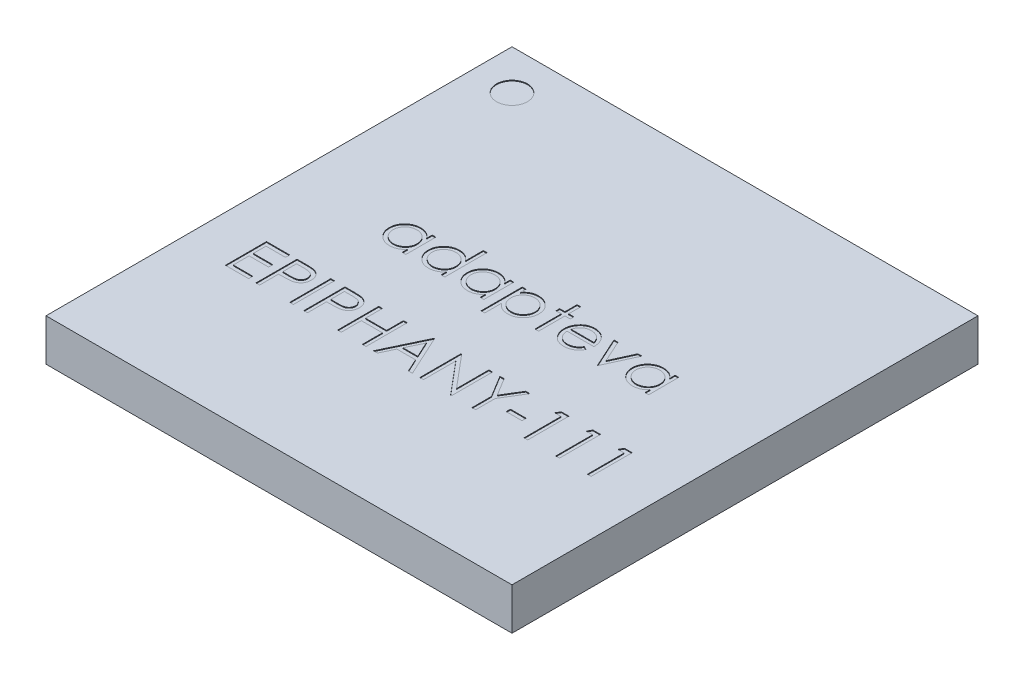
from build123d import *

# Parameters (mm, degrees)
SKETCH1_W           = 15.000224
SKETCH1_H           = 15.000224
BOSS_EXTRUDE1_DEPTH = 1.35
SKETCH2_R           = 0.498417109
SKETCH2_W           = 0.118723291
SKETCH2_H           = 1.322916667
SKETCH2_W_2         = 0.508814103
SKETCH2_H_2         = 0.135683761
CUT_EXTRUDE1_DEPTH  = 0.0254


with BuildPart() as part:
    # Sketch1 → Boss-Extrude1 (new body)
    with BuildSketch(Plane(origin=(0, 0, 0), x_dir=(1, 0, 0), z_dir=(0, 1, 0))):
        with Locations((7.500112, 7.500112)):
            Rectangle(SKETCH1_W, SKETCH1_H)
    extrude(amount=BOSS_EXTRUDE1_DEPTH)

    # Sketch2 → Cut-Extrude1 (cut)
    with BuildSketch(Plane(origin=(0, 1.35, 0), x_dir=(1, 0, 0), z_dir=(0, 1, 0))):
        with Locations((1.283347706, 13.716876294)):
            Circle(SKETCH2_R)
        with BuildLine():
            Line((4.082577278, 8.466858795), (4.082577278, 7.500112))
            Line((4.082577278, 7.500112), (3.963853987, 7.500112))
            Line((3.963853987, 7.500112), (3.963853987, 7.667331635))
            add(Edge.make_bspline(
                [(3.963853987, 7.667331635), (3.950466528, 7.652197622), (3.924340732, 7.622663405), (3.880706738, 7.584078774), (3.83445448, 7.552185777), (3.785808445, 7.526426732), (3.734812562, 7.507077353), (3.681579874, 7.493324252), (3.626088667, 7.484481939), (3.588195664, 7.483598978), (3.568993043, 7.48315153)],
                knots=[0, 0, 0, 0, 6.0575e-05, 0.000118214, 0.000174228, 0.000228757, 0.000282945, 0.000337452, 0.000393484, 0.000451052, 0.000451052, 0.000451052, 0.000451052], degree=3))
            add(Edge.make_bspline(
                [(3.568993043, 7.48315153), (3.551920632, 7.483615069), (3.518253081, 7.48452919), (3.46872721, 7.491620894), (3.421067342, 7.503009552), (3.375228441, 7.51884709), (3.331507124, 7.539855317), (3.289529052, 7.565006325), (3.249511695, 7.594957472), (3.212065012, 7.62919759), (3.177581488, 7.666388552), (3.147320233, 7.70605547), (3.122089158, 7.748026817), (3.100990497, 7.791771194), (3.084738902, 7.837625345), (3.073409582, 7.885430703), (3.06632614, 7.935130745), (3.065412397, 7.968974552), (3.064949073, 7.986135471)],
                knots=[0, 0, 0, 0, 5.1202e-05, 0.000100973, 0.000149758, 0.000198033, 0.00024616, 0.000295017, 0.000344626, 0.000395841, 0.00044704, 0.000496597, 0.000545227, 0.000593707, 0.00064207, 0.000690856, 0.000740889, 0.000792355, 0.000792355, 0.000792355, 0.000792355], degree=3))
            add(Edge.make_bspline(
                [(3.064949073, 7.986135471), (3.065422666, 8.002941692), (3.066358935, 8.036166685), (3.073333812, 8.085030955), (3.085062795, 8.132095893), (3.101522844, 8.177209975), (3.122629774, 8.220427792), (3.148304973, 8.261779909), (3.178550297, 8.301380246), (3.21341951, 8.338297644), (3.251192474, 8.372398889), (3.291601429, 8.402035641), (3.333641181, 8.427630997), (3.377963807, 8.447910734), (3.423913278, 8.464318342), (3.471898658, 8.475670089), (3.521720297, 8.482359255), (3.555545572, 8.483327919), (3.572703146, 8.483819265)],
                knots=[0, 0, 0, 0, 5.0408e-05, 9.9654e-05, 0.00014773, 0.000195684, 0.000243448, 0.000291765, 0.000341482, 0.000392667, 0.000443901, 0.000493936, 0.000542793, 0.000591287, 0.0006399, 0.000688943, 0.000738941, 0.000790407, 0.000790407, 0.000790407, 0.000790407], degree=3))
            add(Edge.make_bspline(
                [(3.572703146, 8.483819265), (3.59243345, 8.483275829), (3.631123644, 8.482210177), (3.687717267, 8.473341825), (3.741255507, 8.458359428), (3.792151646, 8.437979897), (3.840222917, 8.410898384), (3.885014224, 8.37673691), (3.926994332, 8.335710926), (3.95132855, 8.304198883), (3.963853987, 8.287978837)],
                knots=[0, 0, 0, 0, 5.9168e-05, 0.000116027, 0.000171322, 0.000225651, 0.000280117, 0.0003363, 0.000394205, 0.000455625, 0.000455625, 0.000455625, 0.000455625], degree=3))
            Line((3.963853987, 8.287978837), (3.963853987, 8.466858795))
            Line((3.963853987, 8.466858795), (4.082577278, 8.466858795))
        make_face()
        with BuildLine():
            add(Edge.make_bspline(
                [(3.57429319, 8.365095974), (3.556938663, 8.364478498), (3.522683588, 8.363259698), (3.472396123, 8.353744717), (3.424274684, 8.337913337), (3.378559948, 8.316262142), (3.335974044, 8.289036995), (3.297914234, 8.256107186), (3.264069225, 8.218371172), (3.235604494, 8.175999243), (3.212400348, 8.130574786), (3.196084238, 8.08309174), (3.18532354, 8.034406525), (3.184224189, 8.00138551), (3.183672363, 7.984810434)],
                knots=[0, 0, 0, 0, 5.2039e-05, 0.000102716, 0.000152915, 0.00020365, 0.000254077, 0.000304064, 0.000354175, 0.0004057, 0.00045678, 0.000506731, 0.000556003, 0.000605661, 0.000605661, 0.000605661, 0.000605661], degree=3))
            add(Edge.make_bspline(
                [(3.183672363, 7.984810434), (3.184377249, 7.968334412), (3.185784256, 7.935446947), (3.195895382, 7.88669536), (3.212858905, 7.839201123), (3.236006947, 7.793367355), (3.264992665, 7.750813246), (3.298590459, 7.712357902), (3.337125238, 7.67928892), (3.379809147, 7.651606861), (3.425396088, 7.629244837), (3.473336295, 7.613685206), (3.522728575, 7.603639437), (3.556312641, 7.602466019), (3.573233161, 7.601874821)],
                knots=[0, 0, 0, 0, 4.9412e-05, 9.863e-05, 0.000148668, 0.000200341, 0.000252234, 0.000302742, 0.000353102, 0.00040404, 0.000455005, 0.000504951, 0.000554897, 0.000605614, 0.000605614, 0.000605614, 0.000605614], degree=3))
            add(Edge.make_bspline(
                [(3.573233161, 7.601874821), (3.590410857, 7.602502247), (3.62457559, 7.603750137), (3.675012245, 7.613305853), (3.723958257, 7.629093465), (3.770746882, 7.650977956), (3.814333634, 7.678100528), (3.853453368, 7.709853208), (3.88653232, 7.746782686), (3.91457536, 7.787368428), (3.936564282, 7.83186076), (3.952581424, 7.8792341), (3.962051204, 7.929490097), (3.96324475, 7.963834498), (3.963853987, 7.981365339)],
                knots=[0, 0, 0, 0, 5.151e-05, 0.000102448, 0.000153402, 0.00020545, 0.000256996, 0.000307079, 0.000356048, 0.000405224, 0.000454645, 0.000504424, 0.000554841, 0.000607408, 0.000607408, 0.000607408, 0.000607408], degree=3))
            add(Edge.make_bspline(
                [(3.963853987, 7.981365339), (3.96349126, 7.994722197), (3.962777298, 8.021012722), (3.957322886, 8.059614492), (3.948646471, 8.096555513), (3.936420388, 8.131874625), (3.920359695, 8.16537655), (3.900989259, 8.197301841), (3.877968449, 8.227484453), (3.851667847, 8.255508769), (3.822879214, 8.281069961), (3.792416396, 8.303886207), (3.759918477, 8.322629583), (3.725931978, 8.338142206), (3.690397932, 8.350486587), (3.653027192, 8.358721817), (3.61421698, 8.364376462), (3.587741238, 8.364853612), (3.57429319, 8.365095974)],
                knots=[0, 0, 0, 0, 4.0059e-05, 7.8849e-05, 0.000116709, 0.000153753, 0.000190737, 0.000227959, 0.000265591, 0.000304403, 0.00034307, 0.000380967, 0.000418375, 0.000455374, 0.00049292, 0.000530977, 0.00057003, 0.000610342, 0.000610342, 0.000610342, 0.000610342], degree=3))
        make_face(mode=Mode.SUBTRACT)
        with BuildLine():
            Line((5.337652064, 8.856949607), (5.337652064, 7.500112))
            Line((5.337652064, 7.500112), (5.218928774, 7.500112))
            Line((5.218928774, 7.500112), (5.218928774, 7.667331635))
            add(Edge.make_bspline(
                [(5.218928774, 7.667331635), (5.205541314, 7.652197622), (5.179415518, 7.622663405), (5.135781524, 7.584078774), (5.089529267, 7.552185777), (5.040883232, 7.526426732), (4.989887348, 7.507077353), (4.93665466, 7.493324252), (4.881163454, 7.484481939), (4.843270451, 7.483598978), (4.824067829, 7.48315153)],
                knots=[0, 0, 0, 0, 6.0575e-05, 0.000118214, 0.000174228, 0.000228757, 0.000282945, 0.000337452, 0.000393484, 0.000451052, 0.000451052, 0.000451052, 0.000451052], degree=3))
            add(Edge.make_bspline(
                [(4.824067829, 7.48315153), (4.806995418, 7.483615069), (4.773327868, 7.48452919), (4.723801996, 7.491620894), (4.676142128, 7.503009552), (4.630303227, 7.51884709), (4.58658191, 7.539855317), (4.544603838, 7.565006325), (4.504586481, 7.594957472), (4.467139798, 7.62919759), (4.432656274, 7.666388552), (4.402395019, 7.70605547), (4.377163945, 7.748026817), (4.356065283, 7.791771194), (4.339813689, 7.837625345), (4.328484369, 7.885430703), (4.321400926, 7.935130745), (4.320487183, 7.968974552), (4.320023859, 7.986135471)],
                knots=[0, 0, 0, 0, 5.1202e-05, 0.000100973, 0.000149758, 0.000198033, 0.00024616, 0.000295017, 0.000344626, 0.000395841, 0.00044704, 0.000496597, 0.000545227, 0.000593707, 0.00064207, 0.000690856, 0.000740889, 0.000792355, 0.000792355, 0.000792355, 0.000792355], degree=3))
            add(Edge.make_bspline(
                [(4.320023859, 7.986135471), (4.320497452, 8.002941692), (4.321433721, 8.036166685), (4.328408599, 8.085030955), (4.340137581, 8.132095893), (4.356597631, 8.177209975), (4.37770456, 8.220427792), (4.40337976, 8.261779909), (4.433625083, 8.301380246), (4.468494297, 8.338297644), (4.506267261, 8.372398889), (4.546676215, 8.402035641), (4.588715968, 8.427630997), (4.633038594, 8.447910734), (4.678988065, 8.464318342), (4.726973445, 8.475670089), (4.776795083, 8.482359255), (4.810620358, 8.483327919), (4.827777932, 8.483819265)],
                knots=[0, 0, 0, 0, 5.0408e-05, 9.9654e-05, 0.00014773, 0.000195684, 0.000243448, 0.000291765, 0.000341482, 0.000392667, 0.000443901, 0.000493936, 0.000542793, 0.000591287, 0.0006399, 0.000688943, 0.000738941, 0.000790407, 0.000790407, 0.000790407, 0.000790407], degree=3))
            add(Edge.make_bspline(
                [(4.827777932, 8.483819265), (4.847514642, 8.48322694), (4.886255611, 8.482064272), (4.942913683, 8.472347877), (4.996506024, 8.456033337), (5.047341171, 8.43369824), (5.095116061, 8.404669384), (5.140180893, 8.369611545), (5.18175197, 8.327532535), (5.20634757, 8.295929351), (5.218928774, 8.279763609)],
                knots=[0, 0, 0, 0, 5.9182e-05, 0.000116168, 0.000171833, 0.000226886, 0.000282288, 0.000339116, 0.000397769, 0.000459189, 0.000459189, 0.000459189, 0.000459189], degree=3))
            Line((5.218928774, 8.279763609), (5.218928774, 8.856949607))
            Line((5.218928774, 8.856949607), (5.337652064, 8.856949607))
        make_face()
        with BuildLine():
            add(Edge.make_bspline(
                [(4.829367976, 8.365095974), (4.81201345, 8.364478498), (4.777758375, 8.363259698), (4.72747091, 8.353744717), (4.67934947, 8.337913337), (4.633634734, 8.316262142), (4.591048831, 8.289036995), (4.552989021, 8.256107186), (4.519144011, 8.218371172), (4.490679281, 8.175999243), (4.467475134, 8.130574786), (4.451159024, 8.08309174), (4.440398326, 8.034406525), (4.439298975, 8.00138551), (4.43874715, 7.984810434)],
                knots=[0, 0, 0, 0, 5.2039e-05, 0.000102716, 0.000152915, 0.00020365, 0.000254077, 0.000304064, 0.000354175, 0.0004057, 0.00045678, 0.000506731, 0.000556003, 0.000605661, 0.000605661, 0.000605661, 0.000605661], degree=3))
            add(Edge.make_bspline(
                [(4.43874715, 7.984810434), (4.439452035, 7.968334412), (4.440859042, 7.935446947), (4.450970168, 7.88669536), (4.467933692, 7.839201123), (4.491081733, 7.793367355), (4.520067451, 7.750813246), (4.553665246, 7.712357902), (4.592200025, 7.67928892), (4.634883934, 7.651606861), (4.680470875, 7.629244837), (4.728411081, 7.613685206), (4.777803361, 7.603639437), (4.811387428, 7.602466019), (4.828307947, 7.601874821)],
                knots=[0, 0, 0, 0, 4.9412e-05, 9.863e-05, 0.000148668, 0.000200341, 0.000252234, 0.000302742, 0.000353102, 0.00040404, 0.000455005, 0.000504951, 0.000554897, 0.000605614, 0.000605614, 0.000605614, 0.000605614], degree=3))
            add(Edge.make_bspline(
                [(4.828307947, 7.601874821), (4.845485643, 7.602502247), (4.879650376, 7.603750137), (4.930087031, 7.613305853), (4.979033044, 7.629093465), (5.025821669, 7.650977956), (5.069408421, 7.678100528), (5.108528154, 7.709853208), (5.141607106, 7.746782686), (5.169650146, 7.787368428), (5.191639069, 7.83186076), (5.20765621, 7.8792341), (5.21712599, 7.929490097), (5.218319537, 7.963834498), (5.218928774, 7.981365339)],
                knots=[0, 0, 0, 0, 5.151e-05, 0.000102448, 0.000153402, 0.00020545, 0.000256996, 0.000307079, 0.000356048, 0.000405224, 0.000454645, 0.000504424, 0.000554841, 0.000607408, 0.000607408, 0.000607408, 0.000607408], degree=3))
            add(Edge.make_bspline(
                [(5.218928774, 7.981365339), (5.218566046, 7.994722197), (5.217852084, 8.021012722), (5.212397673, 8.059614492), (5.203721257, 8.096555513), (5.191495175, 8.131874625), (5.175434481, 8.16537655), (5.156064046, 8.197301841), (5.133043236, 8.227484453), (5.106742633, 8.255508769), (5.077954, 8.281069961), (5.047491183, 8.303886207), (5.014993264, 8.322629583), (4.981006765, 8.338142206), (4.945472718, 8.350486587), (4.908101978, 8.358721817), (4.869291766, 8.364376462), (4.842816025, 8.364853612), (4.829367976, 8.365095974)],
                knots=[0, 0, 0, 0, 4.0059e-05, 7.8849e-05, 0.000116709, 0.000153753, 0.000190737, 0.000227959, 0.000265591, 0.000304403, 0.00034307, 0.000380967, 0.000418375, 0.000455374, 0.00049292, 0.000530977, 0.00057003, 0.000610342, 0.000610342, 0.000610342, 0.000610342], degree=3))
        make_face(mode=Mode.SUBTRACT)
        with BuildLine():
            Line((6.59272685, 8.466858795), (6.59272685, 7.500112))
            Line((6.59272685, 7.500112), (6.47400356, 7.500112))
            Line((6.47400356, 7.500112), (6.47400356, 7.667331635))
            add(Edge.make_bspline(
                [(6.47400356, 7.667331635), (6.4606161, 7.652197622), (6.434490305, 7.622663405), (6.390856311, 7.584078774), (6.344604053, 7.552185777), (6.295958018, 7.526426732), (6.244962134, 7.507077353), (6.191729446, 7.493324252), (6.13623824, 7.484481939), (6.098345237, 7.483598978), (6.079142616, 7.48315153)],
                knots=[0, 0, 0, 0, 6.0575e-05, 0.000118214, 0.000174228, 0.000228757, 0.000282945, 0.000337452, 0.000393484, 0.000451052, 0.000451052, 0.000451052, 0.000451052], degree=3))
            add(Edge.make_bspline(
                [(6.079142616, 7.48315153), (6.062070205, 7.483615069), (6.028402654, 7.48452919), (5.978876782, 7.491620894), (5.931216914, 7.503009552), (5.885378013, 7.51884709), (5.841656697, 7.539855317), (5.799678624, 7.565006325), (5.759661267, 7.594957472), (5.722214585, 7.62919759), (5.687731061, 7.666388552), (5.657469806, 7.70605547), (5.632238731, 7.748026817), (5.611140069, 7.791771194), (5.594888475, 7.837625345), (5.583559155, 7.885430703), (5.576475712, 7.935130745), (5.57556197, 7.968974552), (5.575098645, 7.986135471)],
                knots=[0, 0, 0, 0, 5.1202e-05, 0.000100973, 0.000149758, 0.000198033, 0.00024616, 0.000295017, 0.000344626, 0.000395841, 0.00044704, 0.000496597, 0.000545227, 0.000593707, 0.00064207, 0.000690856, 0.000740889, 0.000792355, 0.000792355, 0.000792355, 0.000792355], degree=3))
            add(Edge.make_bspline(
                [(5.575098645, 7.986135471), (5.575572239, 8.002941692), (5.576508507, 8.036166685), (5.583483385, 8.085030955), (5.595212367, 8.132095893), (5.611672417, 8.177209975), (5.632779346, 8.220427792), (5.658454546, 8.261779909), (5.68869987, 8.301380246), (5.723569083, 8.338297644), (5.761342047, 8.372398889), (5.801751002, 8.402035641), (5.843790754, 8.427630997), (5.88811338, 8.447910734), (5.934062851, 8.464318342), (5.982048231, 8.475670089), (6.031869869, 8.482359255), (6.065695144, 8.483327919), (6.082852718, 8.483819265)],
                knots=[0, 0, 0, 0, 5.0408e-05, 9.9654e-05, 0.00014773, 0.000195684, 0.000243448, 0.000291765, 0.000341482, 0.000392667, 0.000443901, 0.000493936, 0.000542793, 0.000591287, 0.0006399, 0.000688943, 0.000738941, 0.000790407, 0.000790407, 0.000790407, 0.000790407], degree=3))
            add(Edge.make_bspline(
                [(6.082852718, 8.483819265), (6.102583022, 8.483275829), (6.141273217, 8.482210177), (6.19786684, 8.473341825), (6.25140508, 8.458359428), (6.302301219, 8.437979897), (6.35037249, 8.410898384), (6.395163797, 8.37673691), (6.437143905, 8.335710926), (6.461478122, 8.304198883), (6.47400356, 8.287978837)],
                knots=[0, 0, 0, 0, 5.9168e-05, 0.000116027, 0.000171322, 0.000225651, 0.000280117, 0.0003363, 0.000394205, 0.000455625, 0.000455625, 0.000455625, 0.000455625], degree=3))
            Line((6.47400356, 8.287978837), (6.47400356, 8.466858795))
            Line((6.47400356, 8.466858795), (6.59272685, 8.466858795))
        make_face()
        with BuildLine():
            add(Edge.make_bspline(
                [(6.084442763, 8.365095974), (6.067088236, 8.364478498), (6.032833161, 8.363259698), (5.982545696, 8.353744717), (5.934424257, 8.337913337), (5.88870952, 8.316262142), (5.846123617, 8.289036995), (5.808063807, 8.256107186), (5.774218798, 8.218371172), (5.745754067, 8.175999243), (5.722549921, 8.130574786), (5.70623381, 8.08309174), (5.695473113, 8.034406525), (5.694373761, 8.00138551), (5.693821936, 7.984810434)],
                knots=[0, 0, 0, 0, 5.2039e-05, 0.000102716, 0.000152915, 0.00020365, 0.000254077, 0.000304064, 0.000354175, 0.0004057, 0.00045678, 0.000506731, 0.000556003, 0.000605661, 0.000605661, 0.000605661, 0.000605661], degree=3))
            add(Edge.make_bspline(
                [(5.693821936, 7.984810434), (5.694526821, 7.968334412), (5.695933829, 7.935446947), (5.706044954, 7.88669536), (5.723008478, 7.839201123), (5.74615652, 7.793367355), (5.775142238, 7.750813246), (5.808740032, 7.712357902), (5.847274811, 7.67928892), (5.88995872, 7.651606861), (5.935545661, 7.629244837), (5.983485867, 7.613685206), (6.032878147, 7.603639437), (6.066462214, 7.602466019), (6.083382733, 7.601874821)],
                knots=[0, 0, 0, 0, 4.9412e-05, 9.863e-05, 0.000148668, 0.000200341, 0.000252234, 0.000302742, 0.000353102, 0.00040404, 0.000455005, 0.000504951, 0.000554897, 0.000605614, 0.000605614, 0.000605614, 0.000605614], degree=3))
            add(Edge.make_bspline(
                [(6.083382733, 7.601874821), (6.100560429, 7.602502247), (6.134725163, 7.603750137), (6.185161817, 7.613305853), (6.23410783, 7.629093465), (6.280896455, 7.650977956), (6.324483207, 7.678100528), (6.36360294, 7.709853208), (6.396681893, 7.746782686), (6.424724933, 7.787368428), (6.446713855, 7.83186076), (6.462730996, 7.8792341), (6.472200776, 7.929490097), (6.473394323, 7.963834498), (6.47400356, 7.981365339)],
                knots=[0, 0, 0, 0, 5.151e-05, 0.000102448, 0.000153402, 0.00020545, 0.000256996, 0.000307079, 0.000356048, 0.000405224, 0.000454645, 0.000504424, 0.000554841, 0.000607408, 0.000607408, 0.000607408, 0.000607408], degree=3))
            add(Edge.make_bspline(
                [(6.47400356, 7.981365339), (6.473640833, 7.994722197), (6.472926871, 8.021012722), (6.467472459, 8.059614492), (6.458796043, 8.096555513), (6.446569961, 8.131874625), (6.430509267, 8.16537655), (6.411138832, 8.197301841), (6.388118022, 8.227484453), (6.36181742, 8.255508769), (6.333028787, 8.281069961), (6.302565969, 8.303886207), (6.27006805, 8.322629583), (6.236081551, 8.338142206), (6.200547505, 8.350486587), (6.163176765, 8.358721817), (6.124366552, 8.364376462), (6.097890811, 8.364853612), (6.084442763, 8.365095974)],
                knots=[0, 0, 0, 0, 4.0059e-05, 7.8849e-05, 0.000116709, 0.000153753, 0.000190737, 0.000227959, 0.000265591, 0.000304403, 0.00034307, 0.000380967, 0.000418375, 0.000455374, 0.00049292, 0.000530977, 0.00057003, 0.000610342, 0.000610342, 0.000610342, 0.000610342], degree=3))
        make_face(mode=Mode.SUBTRACT)
        with BuildLine():
            Line((6.864094372, 8.466858795), (6.982817662, 8.466858795))
            Line((6.982817662, 8.466858795), (6.982817662, 8.287978837))
            add(Edge.make_bspline(
                [(6.982817662, 8.287978837), (6.995425997, 8.304208278), (7.019927773, 8.335746949), (7.062157126, 8.376564646), (7.106730652, 8.410988943), (7.154795395, 8.43796984), (7.205604349, 8.458312826), (7.258949005, 8.473348511), (7.315282109, 8.48220883), (7.353796542, 8.483275351), (7.373438489, 8.483819265)],
                knots=[0, 0, 0, 0, 6.1587e-05, 0.000119683, 0.000175654, 0.00023012, 0.000284449, 0.000339489, 0.000396086, 0.000454989, 0.000454989, 0.000454989, 0.000454989], degree=3))
            add(Edge.make_bspline(
                [(7.373438489, 8.483819265), (7.390595434, 8.483322915), (7.424507038, 8.482341852), (7.474423794, 8.475699656), (7.522493061, 8.464315885), (7.568442891, 8.447911373), (7.612765538, 8.427630882), (7.654804843, 8.402035455), (7.695215622, 8.372399782), (7.732981562, 8.338294177), (7.767876841, 8.301393017), (7.798056796, 8.261697087), (7.824088736, 8.220511823), (7.845130783, 8.177198741), (7.8616137, 8.132098913), (7.87333651, 8.085030127), (7.88031306, 8.0361669), (7.881249099, 8.002941764), (7.881722577, 7.986135471)],
                knots=[0, 0, 0, 0, 5.1467e-05, 0.000101727, 0.00015077, 0.000199383, 0.000247876, 0.000296733, 0.000346769, 0.000398003, 0.000449188, 0.000498905, 0.000547362, 0.000595126, 0.00064308, 0.000691156, 0.000740402, 0.00079081, 0.00079081, 0.00079081, 0.00079081], degree=3))
            add(Edge.make_bspline(
                [(7.881722577, 7.986135471), (7.881259373, 7.968974479), (7.880345867, 7.935130527), (7.873260701, 7.885431535), (7.861937716, 7.837622319), (7.845662748, 7.791782401), (7.82463159, 7.747943343), (7.799040878, 7.706136758), (7.768845695, 7.666376043), (7.734336043, 7.629200989), (7.696896392, 7.594956606), (7.656877221, 7.565006502), (7.614899592, 7.539855446), (7.571178267, 7.518846411), (7.525338963, 7.503012163), (7.477595551, 7.491590554), (7.427974026, 7.484547158), (7.394220317, 7.483620307), (7.377148592, 7.48315153)],
                knots=[0, 0, 0, 0, 5.1467e-05, 0.0001015, 0.000150286, 0.000198649, 0.000247128, 0.000295896, 0.000345453, 0.000396652, 0.000447867, 0.000497476, 0.000546333, 0.00059446, 0.000642735, 0.00069152, 0.000741554, 0.000792756, 0.000792756, 0.000792756, 0.000792756], degree=3))
            add(Edge.make_bspline(
                [(7.377148592, 7.48315153), (7.35793698, 7.483640936), (7.319988414, 7.484607658), (7.26450239, 7.494404578), (7.211103103, 7.509046217), (7.160382166, 7.530477087), (7.111937785, 7.557787951), (7.066043989, 7.591091511), (7.022457002, 7.630318116), (6.996222145, 7.660076868), (6.982817662, 7.675281855)],
                knots=[0, 0, 0, 0, 5.758e-05, 0.000113738, 0.000168523, 0.0002234, 0.000278458, 0.00033502, 0.000393188, 0.000453958, 0.000453958, 0.000453958, 0.000453958], degree=3))
            Line((6.982817662, 7.675281855), (6.982817662, 7.143942128))
            Line((6.982817662, 7.143942128), (6.864094372, 7.143942128))
            Line((6.864094372, 7.143942128), (6.864094372, 8.466858795))
        make_face()
        with BuildLine():
            add(Edge.make_bspline(
                [(7.37237846, 8.365095974), (7.358930232, 8.364853972), (7.332454139, 8.364377532), (7.293646484, 8.358717736), (7.256266367, 8.350501387), (7.220690511, 8.338061472), (7.186577927, 8.322791683), (7.154191352, 8.303710685), (7.123553522, 8.281163647), (7.094741519, 8.255582466), (7.068712834, 8.22739501), (7.045670299, 8.197312713), (7.026315156, 8.165373672), (7.010250405, 8.131875395), (6.998025414, 8.096555302), (6.989348698, 8.05961455), (6.983894369, 8.021012706), (6.983180395, 7.994722192), (6.982817662, 7.981365339)],
                knots=[0, 0, 0, 0, 4.0312e-05, 7.9365e-05, 0.000117423, 0.000154968, 0.000192209, 0.000229387, 0.000267498, 0.000306165, 0.000344796, 0.000382428, 0.000419651, 0.000456635, 0.000493679, 0.000531539, 0.000570329, 0.000610388, 0.000610388, 0.000610388, 0.000610388], degree=3))
            add(Edge.make_bspline(
                [(6.982817662, 7.981365339), (6.983418968, 7.963831737), (6.984596977, 7.929481925), (6.994173899, 7.879292689), (7.009759847, 7.831799355), (7.031882307, 7.787401879), (7.059832729, 7.746586939), (7.093509711, 7.710040192), (7.132608533, 7.677991367), (7.176479168, 7.650995834), (7.22350777, 7.629077725), (7.272563755, 7.613386342), (7.322972505, 7.603720649), (7.357053983, 7.602493428), (7.374233511, 7.601874821)],
                knots=[0, 0, 0, 0, 5.2568e-05, 0.000102985, 0.00015268, 0.000202101, 0.000251276, 0.000300603, 0.000350686, 0.000402457, 0.000454745, 0.000505952, 0.000556629, 0.000608139, 0.000608139, 0.000608139, 0.000608139], degree=3))
            add(Edge.make_bspline(
                [(7.374233511, 7.601874821), (7.391066971, 7.602463094), (7.424478363, 7.603630711), (7.473675034, 7.613737109), (7.521485483, 7.629175556), (7.566910727, 7.65168765), (7.609555319, 7.679276154), (7.648064121, 7.712371762), (7.681706615, 7.750732544), (7.710381535, 7.793447068), (7.733487781, 7.839248477), (7.750848318, 7.886639657), (7.760867927, 7.935453552), (7.762287904, 7.968336616), (7.762999286, 7.984810434)],
                knots=[0, 0, 0, 0, 5.0452e-05, 0.000100138, 0.000150084, 0.000200811, 0.000251749, 0.000302109, 0.000352617, 0.000404361, 0.000456034, 0.000506162, 0.00055538, 0.000604791, 0.000604791, 0.000604791, 0.000604791], degree=3))
            add(Edge.make_bspline(
                [(7.762999286, 7.984810434), (7.762449432, 8.001386576), (7.761354006, 8.034409714), (7.750563905, 8.083079026), (7.734348735, 8.130661684), (7.710702903, 8.175837606), (7.68265659, 8.218463524), (7.648734362, 8.25609252), (7.610703835, 8.289040959), (7.568110014, 8.316261069), (7.522397413, 8.337913622), (7.474275406, 8.35374464), (7.423988092, 8.363259718), (7.389732997, 8.364478505), (7.37237846, 8.365095974)],
                knots=[0, 0, 0, 0, 4.9658e-05, 9.893e-05, 0.000148881, 0.000200081, 0.000251458, 0.000301569, 0.000351555, 0.000401983, 0.000452718, 0.000502917, 0.000553594, 0.000605633, 0.000605633, 0.000605633, 0.000605633], degree=3))
        make_face(mode=Mode.SUBTRACT)
        Polygon((8.237892449, 8.856949607), (8.356615739, 8.856949607), (8.356615739, 8.466858795), (8.52622044, 8.466858795), (8.52622044, 8.348135504), (8.356615739, 8.348135504), (8.356615739, 7.500112), (8.237892449, 7.500112), (8.237892449, 8.348135504), (8.068287748, 8.348135504), (8.068287748, 8.466858795), (8.237892449, 8.466858795), align=None)
        with BuildLine():
            Line((9.523178072, 7.805400462), (9.628650996, 7.750013926))
            add(Edge.make_bspline(
                [(9.628650996, 7.750013926), (9.620246092, 7.735105286), (9.603893478, 7.706098977), (9.575771767, 7.666248244), (9.546292621, 7.630398065), (9.514125347, 7.599506202), (9.480232343, 7.572574875), (9.444425655, 7.549012661), (9.40651887, 7.528935125), (9.366510194, 7.512019735), (9.324063638, 7.499013766), (9.279076338, 7.489827349), (9.231462112, 7.484148911), (9.198825312, 7.48348929), (9.182113619, 7.48315153)],
                knots=[0, 0, 0, 0, 5.1314e-05, 9.9836e-05, 0.000146118, 0.000190348, 0.000233349, 0.000275833, 0.000318749, 0.000361864, 0.000405955, 0.000451692, 0.000499453, 0.000549574, 0.000549574, 0.000549574, 0.000549574], degree=3))
            add(Edge.make_bspline(
                [(9.182113619, 7.48315153), (9.163539122, 7.483585135), (9.127305658, 7.484430973), (9.074562956, 7.491723065), (9.024904664, 7.503618867), (8.978333574, 7.520236795), (8.934963734, 7.541942956), (8.894708947, 7.568385974), (8.857357519, 7.599430011), (8.824086464, 7.635343965), (8.794134163, 7.673777323), (8.767703868, 7.713826125), (8.745608351, 7.755389606), (8.727634596, 7.798203167), (8.713118472, 7.84199696), (8.703001295, 7.887169449), (8.697169218, 7.933598375), (8.696275514, 7.96500719), (8.695825141, 7.980835324)],
                knots=[0, 0, 0, 0, 5.5703e-05, 0.00010866, 0.000159373, 0.000208663, 0.000256662, 0.000304511, 0.000352863, 0.000401981, 0.00045107, 0.00049892, 0.000545748, 0.000592064, 0.000638072, 0.000683977, 0.000730718, 0.000778202, 0.000778202, 0.000778202, 0.000778202], degree=3))
            add(Edge.make_bspline(
                [(8.695825141, 7.980835324), (8.696225471, 7.995687834), (8.697018873, 8.025123548), (8.702019795, 8.06869118), (8.710882692, 8.111035267), (8.723044576, 8.152190996), (8.738749958, 8.192089458), (8.757963327, 8.230754934), (8.780714612, 8.268146282), (8.798280176, 8.29173318), (8.807128226, 8.30361427)],
                knots=[0, 0, 0, 0, 4.456e-05, 8.8312e-05, 0.000131346, 0.000174193, 0.000216908, 0.000259811, 0.000303579, 0.000348002, 0.000348002, 0.000348002, 0.000348002], degree=3))
            add(Edge.make_bspline(
                [(8.807128226, 8.30361427), (8.819112975, 8.317927802), (8.842702827, 8.346101448), (8.882600616, 8.383119803), (8.925803369, 8.414130397), (8.971769668, 8.439835475), (9.021033752, 8.459366883), (9.072933395, 8.473921832), (9.128059554, 8.482077807), (9.165745753, 8.483229815), (9.1850287, 8.483819265)],
                knots=[0, 0, 0, 0, 5.5967e-05, 0.000110162, 0.000162749, 0.000215181, 0.000267738, 0.000321359, 0.000376565, 0.000434411, 0.000434411, 0.000434411, 0.000434411], degree=3))
            add(Edge.make_bspline(
                [(9.1850287, 8.483819265), (9.204852646, 8.483307467), (9.243742709, 8.482303435), (9.300451279, 8.472995268), (9.35410905, 8.458234332), (9.40469455, 8.437387512), (9.452212908, 8.410490896), (9.496355254, 8.377175378), (9.53787651, 8.33846378), (9.562032431, 8.308693162), (9.57432449, 8.293543991)],
                knots=[0, 0, 0, 0, 5.9433e-05, 0.000116594, 0.00017189, 0.000226074, 0.00028031, 0.000335219, 0.000391648, 0.000450114, 0.000450114, 0.000450114, 0.000450114], degree=3))
            add(Edge.make_bspline(
                [(9.57432449, 8.293543991), (9.582687946, 8.282127757), (9.599359188, 8.259371277), (9.620241276, 8.222264917), (9.63836803, 8.183442758), (9.652856976, 8.142277259), (9.664589169, 8.099256168), (9.673077312, 8.054071932), (9.678055114, 8.006738007), (9.67903358, 7.974486601), (9.679532406, 7.958044692)],
                knots=[0, 0, 0, 0, 4.2422e-05, 8.4561e-05, 0.000127484, 0.000170819, 0.000215306, 0.000261148, 0.000308588, 0.000357925, 0.000357925, 0.000357925, 0.000357925], degree=3))
            Line((9.679532406, 7.958044692), (8.814548432, 7.958044692))
            add(Edge.make_bspline(
                [(8.814548432, 7.958044692), (8.815130366, 7.945306719), (8.816274717, 7.920258009), (8.821609905, 7.883605362), (8.830019412, 7.848690438), (8.841838373, 7.815775121), (8.856151139, 7.784429508), (8.873683835, 7.754886119), (8.894600869, 7.72727952), (8.917931714, 7.701362775), (8.94390136, 7.678283261), (8.971222518, 7.657626191), (9.000286454, 7.640312766), (9.030864004, 7.626259652), (9.06290572, 7.615258158), (9.096421699, 7.607748595), (9.131345987, 7.602718825), (9.155153094, 7.602159547), (9.167273208, 7.601874821)],
                knots=[0, 0, 0, 0, 3.8236e-05, 7.5189e-05, 0.000110925, 0.000145794, 0.000179943, 0.000214166, 0.000248616, 0.000283699, 0.000318603, 0.000352683, 0.000386315, 0.000419872, 0.000453478, 0.000487742, 0.000522784, 0.000559125, 0.000559125, 0.000559125, 0.000559125], degree=3))
            add(Edge.make_bspline(
                [(9.167273208, 7.601874821), (9.179123195, 7.602104651), (9.202635843, 7.60256068), (9.237651882, 7.606995063), (9.272100453, 7.614165376), (9.305838979, 7.623951175), (9.338182722, 7.635886474), (9.368135653, 7.650288447), (9.395682639, 7.666220047), (9.421429231, 7.684442157), (9.446402493, 7.706745846), (9.471175992, 7.734578396), (9.497738894, 7.767495408), (9.514365913, 7.792270109), (9.523178072, 7.805400462)],
                knots=[0, 0, 0, 0, 3.5536e-05, 7.051e-05, 0.000105696, 0.000141005, 0.000175806, 0.000208996, 0.000240585, 0.000271176, 0.000303461, 0.00034079, 0.000382839, 0.000430255, 0.000430255, 0.000430255, 0.000430255], degree=3))
        make_face()
        with BuildLine():
            add(Edge.make_bspline(
                [(9.560809115, 8.076767983), (9.556463665, 8.092515557), (9.548100072, 8.122824569), (9.530623827, 8.164795381), (9.510942024, 8.202097058), (9.487650477, 8.234444122), (9.461260661, 8.26317164), (9.430778702, 8.288276284), (9.396596088, 8.310734666), (9.358889508, 8.329691116), (9.318959428, 8.345826867), (9.277152921, 8.356646479), (9.234495365, 8.364058419), (9.205642822, 8.364748644), (9.191123869, 8.365095974)],
                knots=[0, 0, 0, 0, 4.8964e-05, 9.424e-05, 0.000136096, 0.00017522, 0.000213477, 0.000252803, 0.000293376, 0.000335924, 0.00037923, 0.000422299, 0.000465256, 0.000508769, 0.000508769, 0.000508769, 0.000508769], degree=3))
            add(Edge.make_bspline(
                [(9.191123869, 8.365095974), (9.179274528, 8.364864777), (9.155850871, 8.364407749), (9.121341241, 8.360072313), (9.088200402, 8.352905943), (9.056183821, 8.343091808), (9.025711052, 8.33001058), (8.996155291, 8.314671086), (8.968268058, 8.295945547), (8.950827747, 8.281673599), (8.942016965, 8.274463462)],
                knots=[0, 0, 0, 0, 3.5536e-05, 7.0247e-05, 0.000104136, 0.000137162, 0.000170532, 0.000203487, 0.00023693, 0.000271075, 0.000271075, 0.000271075, 0.000271075], degree=3))
            add(Edge.make_bspline(
                [(8.942016965, 8.274463462), (8.935707301, 8.26875817), (8.922938081, 8.25721205), (8.905876039, 8.237319463), (8.889539729, 8.215868724), (8.874672545, 8.192039168), (8.861036076, 8.166102147), (8.848275609, 8.138276434), (8.836790268, 8.108350876), (8.830328346, 8.087497007), (8.827003777, 8.076767983)],
                knots=[0, 0, 0, 0, 2.5496e-05, 5.1597e-05, 7.8469e-05, 0.000106335, 0.000135736, 0.000166331, 0.000198124, 0.000231815, 0.000231815, 0.000231815, 0.000231815], degree=3))
            Line((8.827003777, 8.076767983), (9.560809115, 8.076767983))
        make_face(mode=Mode.SUBTRACT)
        Polygon((9.815216167, 8.466858795), (9.943744729, 8.466858795), (10.264668624, 7.762999286), (10.585592519, 8.466858795), (10.714121081, 8.466858795), (10.273148859, 7.500112), (10.256188389, 7.500112), align=None)
        with BuildLine():
            Line((11.901353987, 8.466858795), (11.901353987, 7.500112))
            Line((11.901353987, 7.500112), (11.782630697, 7.500112))
            Line((11.782630697, 7.500112), (11.782630697, 7.667331635))
            add(Edge.make_bspline(
                [(11.782630697, 7.667331635), (11.769243237, 7.652197622), (11.743117441, 7.622663405), (11.699483447, 7.584078774), (11.65323119, 7.552185777), (11.604585155, 7.526426732), (11.553589271, 7.507077353), (11.500356583, 7.493324252), (11.444865377, 7.484481939), (11.406972374, 7.483598978), (11.387769752, 7.48315153)],
                knots=[0, 0, 0, 0, 6.0575e-05, 0.000118214, 0.000174228, 0.000228757, 0.000282945, 0.000337452, 0.000393484, 0.000451052, 0.000451052, 0.000451052, 0.000451052], degree=3))
            add(Edge.make_bspline(
                [(11.387769752, 7.48315153), (11.370697341, 7.483615069), (11.337029791, 7.48452919), (11.287503919, 7.491620894), (11.239844051, 7.503009552), (11.19400515, 7.51884709), (11.150283833, 7.539855317), (11.108305761, 7.565006325), (11.068288404, 7.594957472), (11.030841721, 7.62919759), (10.996358197, 7.666388552), (10.966096943, 7.70605547), (10.940865868, 7.748026817), (10.919767206, 7.791771194), (10.903515612, 7.837625345), (10.892186292, 7.885430703), (10.885102849, 7.935130745), (10.884189106, 7.968974552), (10.883725782, 7.986135471)],
                knots=[0, 0, 0, 0, 5.1202e-05, 0.000100973, 0.000149758, 0.000198033, 0.00024616, 0.000295017, 0.000344626, 0.000395841, 0.00044704, 0.000496597, 0.000545227, 0.000593707, 0.00064207, 0.000690856, 0.000740889, 0.000792355, 0.000792355, 0.000792355, 0.000792355], degree=3))
            add(Edge.make_bspline(
                [(10.883725782, 7.986135471), (10.884199375, 8.002941692), (10.885135644, 8.036166685), (10.892110522, 8.085030955), (10.903839504, 8.132095893), (10.920299554, 8.177209975), (10.941406483, 8.220427792), (10.967081683, 8.261779909), (10.997327007, 8.301380246), (11.03219622, 8.338297644), (11.069969184, 8.372398889), (11.110378138, 8.402035641), (11.152417891, 8.427630997), (11.196740517, 8.447910734), (11.242689988, 8.464318342), (11.290675368, 8.475670089), (11.340497006, 8.482359255), (11.374322281, 8.483327919), (11.391479855, 8.483819265)],
                knots=[0, 0, 0, 0, 5.0408e-05, 9.9654e-05, 0.00014773, 0.000195684, 0.000243448, 0.000291765, 0.000341482, 0.000392667, 0.000443901, 0.000493936, 0.000542793, 0.000591287, 0.0006399, 0.000688943, 0.000738941, 0.000790407, 0.000790407, 0.000790407, 0.000790407], degree=3))
            add(Edge.make_bspline(
                [(11.391479855, 8.483819265), (11.411210159, 8.483275829), (11.449900354, 8.482210177), (11.506493976, 8.473341825), (11.560032217, 8.458359428), (11.610928356, 8.437979897), (11.658999627, 8.410898384), (11.703790933, 8.37673691), (11.745771042, 8.335710926), (11.770105259, 8.304198883), (11.782630697, 8.287978837)],
                knots=[0, 0, 0, 0, 5.9168e-05, 0.000116027, 0.000171322, 0.000225651, 0.000280117, 0.0003363, 0.000394205, 0.000455625, 0.000455625, 0.000455625, 0.000455625], degree=3))
            Line((11.782630697, 8.287978837), (11.782630697, 8.466858795))
            Line((11.782630697, 8.466858795), (11.901353987, 8.466858795))
        make_face()
        with BuildLine():
            add(Edge.make_bspline(
                [(11.393069899, 8.365095974), (11.375715373, 8.364478498), (11.341460298, 8.363259698), (11.291172833, 8.353744717), (11.243051393, 8.337913337), (11.197336657, 8.316262142), (11.154750754, 8.289036995), (11.116690944, 8.256107186), (11.082845935, 8.218371172), (11.054381204, 8.175999243), (11.031177058, 8.130574786), (11.014860947, 8.08309174), (11.00410025, 8.034406525), (11.003000898, 8.00138551), (11.002449073, 7.984810434)],
                knots=[0, 0, 0, 0, 5.2039e-05, 0.000102716, 0.000152915, 0.00020365, 0.000254077, 0.000304064, 0.000354175, 0.0004057, 0.00045678, 0.000506731, 0.000556003, 0.000605661, 0.000605661, 0.000605661, 0.000605661], degree=3))
            add(Edge.make_bspline(
                [(11.002449073, 7.984810434), (11.003153958, 7.968334412), (11.004560966, 7.935446947), (11.014672091, 7.88669536), (11.031635615, 7.839201123), (11.054783656, 7.793367355), (11.083769375, 7.750813246), (11.117367169, 7.712357902), (11.155901948, 7.67928892), (11.198585857, 7.651606861), (11.244172798, 7.629244837), (11.292113004, 7.613685206), (11.341505284, 7.603639437), (11.375089351, 7.602466019), (11.39200987, 7.601874821)],
                knots=[0, 0, 0, 0, 4.9412e-05, 9.863e-05, 0.000148668, 0.000200341, 0.000252234, 0.000302742, 0.000353102, 0.00040404, 0.000455005, 0.000504951, 0.000554897, 0.000605614, 0.000605614, 0.000605614, 0.000605614], degree=3))
            add(Edge.make_bspline(
                [(11.39200987, 7.601874821), (11.409187566, 7.602502247), (11.4433523, 7.603750137), (11.493788954, 7.613305853), (11.542734967, 7.629093465), (11.589523592, 7.650977956), (11.633110344, 7.678100528), (11.672230077, 7.709853208), (11.705309029, 7.746782686), (11.733352069, 7.787368428), (11.755340992, 7.83186076), (11.771358133, 7.8792341), (11.780827913, 7.929490097), (11.78202146, 7.963834498), (11.782630697, 7.981365339)],
                knots=[0, 0, 0, 0, 5.151e-05, 0.000102448, 0.000153402, 0.00020545, 0.000256996, 0.000307079, 0.000356048, 0.000405224, 0.000454645, 0.000504424, 0.000554841, 0.000607408, 0.000607408, 0.000607408, 0.000607408], degree=3))
            add(Edge.make_bspline(
                [(11.782630697, 7.981365339), (11.782267969, 7.994722197), (11.781554007, 8.021012722), (11.776099596, 8.059614492), (11.76742318, 8.096555513), (11.755197098, 8.131874625), (11.739136404, 8.16537655), (11.719765969, 8.197301841), (11.696745159, 8.227484453), (11.670444556, 8.255508769), (11.641655923, 8.281069961), (11.611193106, 8.303886207), (11.578695187, 8.322629583), (11.544708688, 8.338142206), (11.509174642, 8.350486587), (11.471803901, 8.358721817), (11.432993689, 8.364376462), (11.406517948, 8.364853612), (11.393069899, 8.365095974)],
                knots=[0, 0, 0, 0, 4.0059e-05, 7.8849e-05, 0.000116709, 0.000153753, 0.000190737, 0.000227959, 0.000265591, 0.000304403, 0.00034307, 0.000380967, 0.000418375, 0.000455374, 0.00049292, 0.000530977, 0.00057003, 0.000610342, 0.000610342, 0.000610342, 0.000610342], degree=3))
        make_face(mode=Mode.SUBTRACT)
        Polygon((1.47914512, 5.618167556), (2.225405803, 5.618167556), (2.225405803, 5.482483795), (1.59786841, 5.482483795), (1.59786841, 5.075432513), (2.225405803, 5.075432513), (2.225405803, 4.939748752), (1.59786841, 4.939748752), (1.59786841, 4.43093465), (2.225405803, 4.43093465), (2.225405803, 4.295250889), (1.47914512, 4.295250889), align=None)
        with BuildLine():
            Line((2.462852385, 5.618167556), (2.722294575, 5.618167556))
            add(Edge.make_bspline(
                [(2.722294575, 5.618167556), (2.740139174, 5.61814794), (2.774330217, 5.618110356), (2.82335942, 5.616970854), (2.867888693, 5.61544886), (2.907822022, 5.613339037), (2.943282273, 5.610845683), (2.97410899, 5.607348633), (3.000544478, 5.603697271), (3.016384118, 5.599985013), (3.023607927, 5.598292005)],
                knots=[0, 0, 0, 0, 5.3532e-05, 0.00010257, 0.00014712, 0.000187192, 0.000222537, 0.000253734, 0.000280269, 0.000302517, 0.000302517, 0.000302517, 0.000302517], degree=3))
            add(Edge.make_bspline(
                [(3.023607927, 5.598292005), (3.032752507, 5.595789065), (3.050826185, 5.590842165), (3.076869139, 5.580934002), (3.101646932, 5.569185683), (3.125244575, 5.555796278), (3.147372088, 5.540191317), (3.16835961, 5.523003373), (3.188021924, 5.503835607), (3.206248462, 5.482903006), (3.222987061, 5.460556974), (3.237399173, 5.436463929), (3.249466905, 5.411029419), (3.259817129, 5.384271134), (3.267266456, 5.355964375), (3.27287823, 5.326305826), (3.276440137, 5.295298666), (3.276781284, 5.274109371), (3.276954949, 5.26332272)],
                knots=[0, 0, 0, 0, 2.843e-05, 5.619e-05, 8.3455e-05, 0.000110639, 0.000137472, 0.000164584, 0.000191945, 0.000219742, 0.00024778, 0.000275594, 0.000303805, 0.000332154, 0.000361533, 0.000391471, 0.000422667, 0.000455016, 0.000455016, 0.000455016, 0.000455016], degree=3))
            add(Edge.make_bspline(
                [(3.276954949, 5.26332272), (3.27679566, 5.252445406), (3.276484001, 5.231163206), (3.272743441, 5.200028253), (3.267704946, 5.170274576), (3.259957548, 5.141968147), (3.249810523, 5.115277067), (3.237907277, 5.089793446), (3.223550407, 5.065950832), (3.2070537, 5.043662666), (3.188702354, 5.022908026), (3.168574011, 5.003837315), (3.146749933, 4.986562163), (3.123299478, 4.971043843), (3.09799403, 4.957642214), (3.071217382, 4.945638709), (3.042736795, 4.935557683), (3.023028166, 4.930254653), (3.013007633, 4.927558414)],
                knots=[0, 0, 0, 0, 3.2613e-05, 6.381e-05, 9.396e-05, 0.000123083, 0.000151681, 0.000179538, 0.000207352, 0.00023502, 0.000262618, 0.000290361, 0.000318091, 0.000346021, 0.000374595, 0.000403898, 0.000433989, 0.000465112, 0.000465112, 0.000465112, 0.000465112], degree=3))
            add(Edge.make_bspline(
                [(3.013007633, 4.927558414), (3.004719623, 4.925795918), (2.986555967, 4.921933306), (2.956641902, 4.917621181), (2.92181314, 4.9139406), (2.882117219, 4.911180944), (2.83758977, 4.908818453), (2.788206705, 4.906940632), (2.733871087, 4.905908813), (2.695970944, 4.905855596), (2.676183297, 4.905827812)],
                knots=[0, 0, 0, 0, 2.5414e-05, 5.5697e-05, 9.0611e-05, 0.000130469, 0.000175054, 0.00022438, 0.000278717, 0.000338079, 0.000338079, 0.000338079, 0.000338079], degree=3))
            Line((2.676183297, 4.905827812), (2.581575675, 4.905827812))
            Line((2.581575675, 4.905827812), (2.581575675, 4.295250889))
            Line((2.581575675, 4.295250889), (2.462852385, 4.295250889))
            Line((2.462852385, 4.295250889), (2.462852385, 5.618167556))
        make_face()
        with BuildLine():
            Line((2.581575675, 5.482483795), (2.581575675, 5.041511573))
            Line((2.581575675, 5.041511573), (2.813192095, 5.038596492))
            add(Edge.make_bspline(
                [(2.813192095, 5.038596492), (2.824501114, 5.038590647), (2.846332944, 5.038579364), (2.877869849, 5.040085683), (2.907128717, 5.041824575), (2.934019672, 5.044370594), (2.958554838, 5.047969402), (2.980775124, 5.05160241), (3.000508234, 5.056858306), (3.023602278, 5.063935181), (3.049336162, 5.076004949), (3.077331932, 5.093524104), (3.101057719, 5.115855205), (3.121588742, 5.140963344), (3.137881737, 5.168895455), (3.149809151, 5.198781631), (3.156817267, 5.230315371), (3.157756989, 5.251893329), (3.158231658, 5.262792706)],
                knots=[0, 0, 0, 0, 3.3922e-05, 6.5486e-05, 9.4695e-05, 0.000121856, 0.000146479, 0.000169091, 0.000189338, 0.000207693, 0.00024149, 0.000274275, 0.000306345, 0.000338752, 0.000371295, 0.000402938, 0.000434959, 0.000467642, 0.000467642, 0.000467642, 0.000467642], degree=3))
            add(Edge.make_bspline(
                [(3.158231658, 5.262792706), (3.157754408, 5.273428394), (3.156805693, 5.294570826), (3.149754221, 5.325556845), (3.137904927, 5.355128079), (3.121479369, 5.382710168), (3.101544478, 5.407727959), (3.078374785, 5.429460505), (3.052024832, 5.446931208), (3.027513745, 5.458207478), (3.005741868, 5.465092418), (2.986830979, 5.469909664), (2.965478849, 5.473755801), (2.941678527, 5.476870137), (2.915614486, 5.479536178), (2.887062801, 5.481345163), (2.856131633, 5.482404047), (2.834658589, 5.482456569), (2.823527381, 5.482483795)],
                knots=[0, 0, 0, 0, 3.189e-05, 6.3394e-05, 9.479e-05, 0.000127105, 0.000159345, 0.000190472, 0.000222004, 0.000253783, 0.000271048, 0.000290458, 0.000312289, 0.000336088, 0.000362457, 0.000390874, 0.000421898, 0.00045529, 0.00045529, 0.00045529, 0.00045529], degree=3))
            Line((2.823527381, 5.482483795), (2.581575675, 5.482483795))
        make_face(mode=Mode.SUBTRACT)
        with Locations((3.607684116, 4.956709223)):
            Rectangle(SKETCH2_W, SKETCH2_H)
        with BuildLine():
            Line((4.006255162, 5.618167556), (4.265697353, 5.618167556))
            add(Edge.make_bspline(
                [(4.265697353, 5.618167556), (4.283541952, 5.61814794), (4.317732995, 5.618110356), (4.366762197, 5.616970854), (4.411291471, 5.61544886), (4.451224799, 5.613339037), (4.486685051, 5.610845683), (4.517511768, 5.607348633), (4.543947255, 5.603697271), (4.559786895, 5.599985013), (4.567010705, 5.598292005)],
                knots=[0, 0, 0, 0, 5.3532e-05, 0.00010257, 0.00014712, 0.000187192, 0.000222537, 0.000253734, 0.000280269, 0.000302517, 0.000302517, 0.000302517, 0.000302517], degree=3))
            add(Edge.make_bspline(
                [(4.567010705, 5.598292005), (4.576155284, 5.595789065), (4.594228963, 5.590842165), (4.620271917, 5.580934002), (4.64504971, 5.569185683), (4.668647352, 5.555796278), (4.690774866, 5.540191317), (4.711762387, 5.523003373), (4.731424701, 5.503835607), (4.749651239, 5.482903006), (4.766389838, 5.460556974), (4.780801951, 5.436463929), (4.792869682, 5.411029419), (4.803219907, 5.384271134), (4.810669234, 5.355964375), (4.816281008, 5.326305826), (4.819842915, 5.295298666), (4.820184062, 5.274109371), (4.820357726, 5.26332272)],
                knots=[0, 0, 0, 0, 2.843e-05, 5.619e-05, 8.3455e-05, 0.000110639, 0.000137472, 0.000164584, 0.000191945, 0.000219742, 0.00024778, 0.000275594, 0.000303805, 0.000332154, 0.000361533, 0.000391471, 0.000422667, 0.000455016, 0.000455016, 0.000455016, 0.000455016], degree=3))
            add(Edge.make_bspline(
                [(4.820357726, 5.26332272), (4.820198438, 5.252445406), (4.819886779, 5.231163206), (4.816146219, 5.200028253), (4.811107724, 5.170274576), (4.803360326, 5.141968147), (4.793213301, 5.115277067), (4.781310055, 5.089793446), (4.766953185, 5.065950832), (4.750456478, 5.043662666), (4.732105132, 5.022908026), (4.711976789, 5.003837315), (4.690152711, 4.986562163), (4.666702256, 4.971043843), (4.641396807, 4.957642214), (4.61462016, 4.945638709), (4.586139572, 4.935557683), (4.566430944, 4.930254653), (4.556410411, 4.927558414)],
                knots=[0, 0, 0, 0, 3.2613e-05, 6.381e-05, 9.396e-05, 0.000123083, 0.000151681, 0.000179538, 0.000207352, 0.00023502, 0.000262618, 0.000290361, 0.000318091, 0.000346021, 0.000374595, 0.000403898, 0.000433989, 0.000465112, 0.000465112, 0.000465112, 0.000465112], degree=3))
            add(Edge.make_bspline(
                [(4.556410411, 4.927558414), (4.548122401, 4.925795918), (4.529958744, 4.921933306), (4.50004468, 4.917621181), (4.465215918, 4.9139406), (4.425519997, 4.911180944), (4.380992547, 4.908818453), (4.331609483, 4.906940632), (4.277273864, 4.905908813), (4.239373722, 4.905855596), (4.219586075, 4.905827812)],
                knots=[0, 0, 0, 0, 2.5414e-05, 5.5697e-05, 9.0611e-05, 0.000130469, 0.000175054, 0.00022438, 0.000278717, 0.000338079, 0.000338079, 0.000338079, 0.000338079], degree=3))
            Line((4.219586075, 4.905827812), (4.124978453, 4.905827812))
            Line((4.124978453, 4.905827812), (4.124978453, 4.295250889))
            Line((4.124978453, 4.295250889), (4.006255162, 4.295250889))
            Line((4.006255162, 4.295250889), (4.006255162, 5.618167556))
        make_face()
        with BuildLine():
            Line((4.124978453, 5.482483795), (4.124978453, 5.041511573))
            Line((4.124978453, 5.041511573), (4.356594873, 5.038596492))
            add(Edge.make_bspline(
                [(4.356594873, 5.038596492), (4.367903892, 5.038590647), (4.389735721, 5.038579364), (4.421272627, 5.040085683), (4.450531495, 5.041824575), (4.47742245, 5.044370594), (4.501957616, 5.047969402), (4.524177902, 5.05160241), (4.543911012, 5.056858306), (4.567005056, 5.063935181), (4.59273894, 5.076004949), (4.62073471, 5.093524104), (4.644460497, 5.115855205), (4.66499152, 5.140963344), (4.681284515, 5.168895455), (4.693211929, 5.198781631), (4.700220045, 5.230315371), (4.701159767, 5.251893329), (4.701634436, 5.262792706)],
                knots=[0, 0, 0, 0, 3.3922e-05, 6.5486e-05, 9.4695e-05, 0.000121856, 0.000146479, 0.000169091, 0.000189338, 0.000207693, 0.00024149, 0.000274275, 0.000306345, 0.000338752, 0.000371295, 0.000402938, 0.000434959, 0.000467642, 0.000467642, 0.000467642, 0.000467642], degree=3))
            add(Edge.make_bspline(
                [(4.701634436, 5.262792706), (4.701157186, 5.273428394), (4.700208471, 5.294570826), (4.693156999, 5.325556845), (4.681307705, 5.355128079), (4.664882147, 5.382710168), (4.644947255, 5.407727959), (4.621777563, 5.429460505), (4.59542761, 5.446931208), (4.570916523, 5.458207478), (4.549144646, 5.465092418), (4.530233756, 5.469909664), (4.508881626, 5.473755801), (4.485081305, 5.476870137), (4.459017264, 5.479536178), (4.430465579, 5.481345163), (4.39953441, 5.482404047), (4.378061367, 5.482456569), (4.366930159, 5.482483795)],
                knots=[0, 0, 0, 0, 3.189e-05, 6.3394e-05, 9.479e-05, 0.000127105, 0.000159345, 0.000190472, 0.000222004, 0.000253783, 0.000271048, 0.000290458, 0.000312289, 0.000336088, 0.000362457, 0.000390874, 0.000421898, 0.00045529, 0.00045529, 0.00045529, 0.00045529], degree=3))
            Line((4.366930159, 5.482483795), (4.124978453, 5.482483795))
        make_face(mode=Mode.SUBTRACT)
        Polygon((5.091725248, 5.618167556), (5.210448538, 5.618167556), (5.210448538, 5.075432513), (5.888867342, 5.075432513), (5.888867342, 5.618167556), (6.007590632, 5.618167556), (6.007590632, 4.295250889), (5.888867342, 4.295250889), (5.888867342, 4.939748752), (5.210448538, 4.939748752), (5.210448538, 4.295250889), (5.091725248, 4.295250889), align=None)
        Polygon((6.889535077, 5.618167556), (7.500112, 4.295250889), (7.371053423, 4.295250889), (7.175478002, 4.719262641), (6.57576638, 4.719262641), (6.374625805, 4.295250889), (6.245037214, 4.295250889), (6.872574607, 5.618167556), align=None)
        Polygon((6.879729805, 5.360315409), (6.640163165, 4.854946402), (7.112936269, 4.854946402), align=None, mode=Mode.SUBTRACT)
        Polygon((7.737558581, 4.295250889), (7.737558581, 5.618167556), (7.762469272, 5.618167556), (8.636463496, 4.576953697), (8.636463496, 5.618167556), (8.755186786, 5.618167556), (8.755186786, 4.295250889), (8.728156037, 4.295250889), (7.856281872, 5.334079682), (7.856281872, 4.295250889), align=None)
        Polygon((8.992633368, 5.618167556), (9.128582136, 5.618167556), (9.476271772, 5.0497268), (9.823431394, 5.618167556), (9.959380162, 5.618167556), (9.53536841, 4.924113319), (9.53536841, 4.295250889), (9.41664512, 4.295250889), (9.41664512, 4.924113319), align=None)
        with Locations((10.332510505, 4.804064992)):
            Rectangle(SKETCH2_W_2, SKETCH2_H_2)
        Polygon((10.969853169, 5.618167556), (11.214454949, 5.618167556), (11.214454949, 4.295250889), (11.095731658, 4.295250889), (11.095731658, 5.482483795), (10.892206017, 5.482483795), align=None)
        Polygon((11.987481374, 5.618167556), (12.232083154, 5.618167556), (12.232083154, 4.295250889), (12.113359863, 4.295250889), (12.113359863, 5.482483795), (11.909834222, 5.482483795), align=None)
        Polygon((13.005109579, 5.618167556), (13.249711359, 5.618167556), (13.249711359, 4.295250889), (13.130988068, 4.295250889), (13.130988068, 5.482483795), (12.927462427, 5.482483795), align=None)
    extrude(amount=-CUT_EXTRUDE1_DEPTH, mode=Mode.SUBTRACT)


solid = part.part
